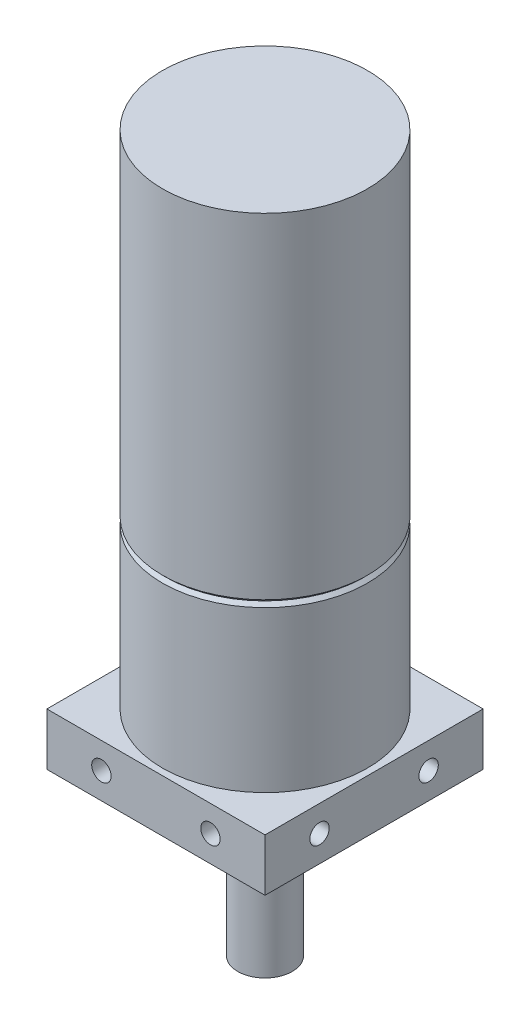
from build123d import *

# Parameters (mm, degrees)
SKETCH1_W                      = 25.4
SKETCH1_H                      = 25.4
EXTRUDE1_DEPTH                 = 6.096
SKETCH2_R                      = 11.938
EXTRUDE2_DEPTH                 = 58.42
SKETCH3_R                      = 3.175
EXTRUDE3_DEPTH                 = 18.796
F_4_40_TAPPED_HOLE3_D          = 2.2606
F_4_40_TAPPED_HOLE3_DEPTH      = 3.048
F_4_40_TAPPED_HOLE3_TIP        = 0.679152758
F_4_40_TAPPED_HOLE4_AT_2_COUNT = 2
F_4_40_TAPPED_HOLE4_AT_2_PITCH = 12.7
CIRPATTERN1_COUNT              = 4


with BuildPart() as part:
    # Sketch1 → Extrude1 (new body)
    with BuildSketch(Plane(origin=(0, 0, 0), x_dir=(1, 0, 0), z_dir=(0, 1, 0))):
        Rectangle(SKETCH1_W, SKETCH1_H)
    extrude(amount=EXTRUDE1_DEPTH)

    # Sketch2 → Extrude2 (add)
    with BuildSketch(Plane(origin=(0, 6.096, 0), x_dir=(1, 0, 0), z_dir=(0, 1, 0))):
        with Locations(Location((0, 0, 0), (0, 0, 270))):  # turned: the seam where the file's is
            Circle(SKETCH2_R)
    extrude(amount=EXTRUDE2_DEPTH)

    # Sketch3 → Extrude3 (add)
    with BuildSketch(Plane.XZ):
        with Locations(Location((0, 0, 0), (0, 0, 90))):  # turned: the seam where the file's is
            Circle(SKETCH3_R)
    extrude(amount=EXTRUDE3_DEPTH)

    # #4-40 Tapped Hole3
    with Locations(Plane(origin=(6.35, 0, -6.35), x_dir=(0, 0, -1), z_dir=(0, -1, 0))):
        with Locations((0, 0), (-12.7, 0), (-12.7, -12.7), (0, -12.7)):
            Hole(F_4_40_TAPPED_HOLE3_D / 2, depth=F_4_40_TAPPED_HOLE3_DEPTH)
            with Locations((0, 0, -(F_4_40_TAPPED_HOLE3_DEPTH + F_4_40_TAPPED_HOLE3_TIP / 2))):  # 118° drill point
                Cone(0, F_4_40_TAPPED_HOLE3_D / 2, F_4_40_TAPPED_HOLE3_TIP, mode=Mode.SUBTRACT)

    # Sketch12 → #4-40 Tapped Hole4 (revolve, cut)
    with BuildSketch(Plane(origin=(-12.7, 3.048, -6.35), x_dir=(0, 0, 1), z_dir=(0, 1, 0))):
        Polygon((0, 0), (0, 4.870152758), (1.1303, 4.191), (1.1303, 0), align=None)
    f_4_40_tapped_hole4 = revolve(axis=Axis((-19.05, 3.048, -6.35), (1, 0, 0)), mode=Mode.SUBTRACT)

    # #4-40 Tapped Hole4 at 2: #4-40 Tapped Hole4 ×2
    with Locations(*[(0, 0, i * F_4_40_TAPPED_HOLE4_AT_2_PITCH) for i in range(1, F_4_40_TAPPED_HOLE4_AT_2_COUNT)]):
        add(f_4_40_tapped_hole4, mode=Mode.SUBTRACT)

    # CirPattern1: #4-40 Tapped Hole4 ×4 about axis
    cirpattern1_axis = Axis((0, -18.796, 0), (0, 1, 0))
    for i in range(1, CIRPATTERN1_COUNT):
        add(f_4_40_tapped_hole4.rotate(cirpattern1_axis, i * 360 / CIRPATTERN1_COUNT), mode=Mode.SUBTRACT)

    # CirPattern1 copy 1 sketch → CirPattern1 copy 1 (revolve, cut)
    with BuildSketch(Plane(origin=(6.35, 3.048, 12.7), x_dir=(1, 0, 0), z_dir=(0, 1, 0))):
        Polygon((0, 0), (0, 4.870152758), (1.1303, 4.191), (1.1303, 0), align=None)
    revolve(axis=Axis((6.35, 3.048, 19.05), (0, 0, -1)), mode=Mode.SUBTRACT)

    # CirPattern1 copy 2 sketch → CirPattern1 copy 2 (revolve, cut)
    with BuildSketch(Plane(origin=(12.7, 3.048, -6.35), x_dir=(0, 0, -1), z_dir=(0, 1, 0))):
        Polygon((0, 0), (0, 4.870152758), (1.1303, 4.191), (1.1303, 0), align=None)
    revolve(axis=Axis((19.05, 3.048, -6.35), (-1, 0, 0)), mode=Mode.SUBTRACT)

    # CirPattern1 copy 3 sketch → CirPattern1 copy 3 (revolve, cut)
    with BuildSketch(Plane(origin=(-6.35, 3.048, -12.7), x_dir=(-1, 0, 0), z_dir=(0, 1, 0))):
        Polygon((0, 0), (0, 4.870152758), (1.1303, 4.191), (1.1303, 0), align=None)
    revolve(axis=Axis((-6.35, 3.048, -19.05), (0, 0, 1)), mode=Mode.SUBTRACT)

    # Sketch13 → Cut-Revolve1 (revolve, cut)
    with BuildSketch(Plane.XY, mode=Mode.PRIVATE) as cut_revolve1_sk:
        Polygon((-11.938, 25.542875), (-11.541125, 25.146), (-11.938, 24.749125), align=None)
    revolve(cut_revolve1_sk.sketch.rotate(Axis((0, 64.516, 0), (0, -1, 0)), 270), axis=Axis((0, 64.516, 0), (0, -1, 0)), mode=Mode.SUBTRACT)  # turned: the seam where the file's is


solid = part.part
